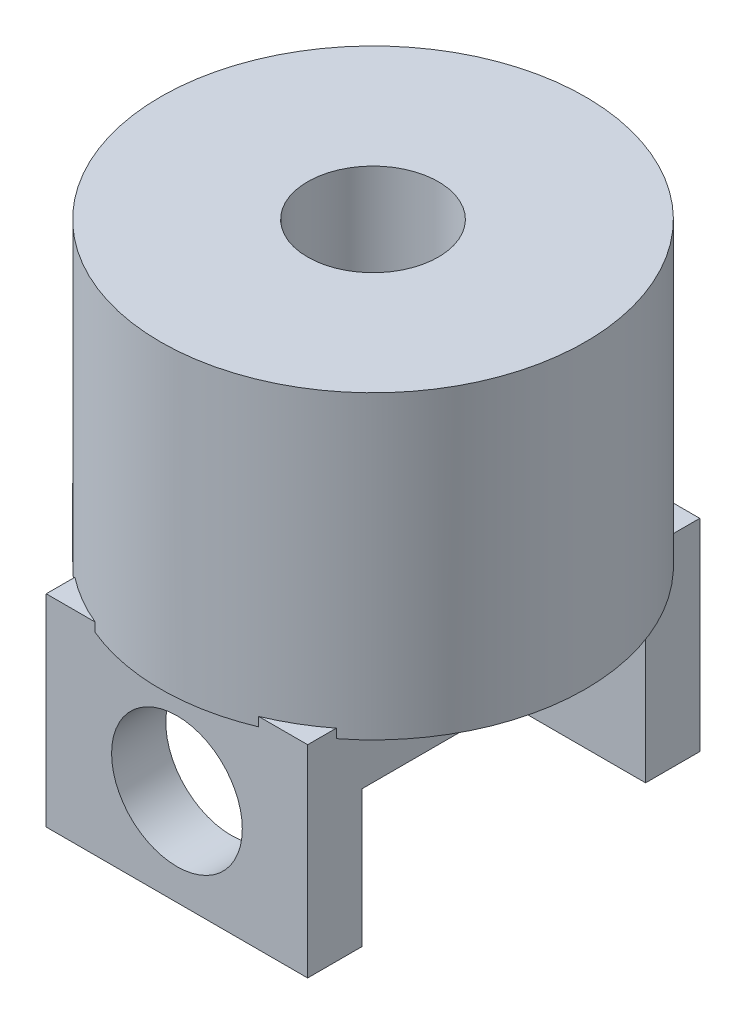
from build123d import *

# Parameters (mm, degrees)
SKETCH1_R           = 32.5
BOSS_EXTRUDE1_DEPTH = 46
SKETCH2_R           = 10
CUT_EXTRUDE1_DEPTH  = 40
BOSS_EXTRUDE2_DEPTH = 20
SKETCH4_R           = 10
CUT_EXTRUDE2_DEPTH  = 42


with BuildPart() as part:
    # Sketch1 → Boss-Extrude1 (new body)
    with BuildSketch(Plane(origin=(0, 0, 0), x_dir=(1, 0, 0), z_dir=(0, 1, 0))):
        Circle(SKETCH1_R)
    extrude(amount=BOSS_EXTRUDE1_DEPTH)

    # Sketch2 → Cut-Extrude1 (cut)
    with BuildSketch(Plane(origin=(0, 46, 0), x_dir=(1, 0, 0), z_dir=(0, 1, 0))):
        Circle(SKETCH2_R)
    extrude(amount=-CUT_EXTRUDE1_DEPTH, mode=Mode.SUBTRACT)

    # Sketch3 → Boss-Extrude2 (add, symmetric)
    with BuildSketch(Plane(origin=(0, 0, 0), x_dir=(0, 0, -1), z_dir=(1, 0, 0))):
        Polygon((30, 1.387692851), (-30, 1.387692851), (-30, -29.525977517), (-21.708955771, -29.525977517), (-21.708955771, -8.612307149), (21.708955771, -8.612307149), (21.708955771, -29.525977517), (30, -29.525977517), align=None)
    extrude(amount=BOSS_EXTRUDE2_DEPTH, both=True)

    # Sketch4 → Cut-Extrude2 (cut, symmetric)
    with BuildSketch(Plane.XY):
        with Locations((0, -14.762988758)):
            Circle(SKETCH4_R)
    extrude(amount=CUT_EXTRUDE2_DEPTH, both=True, mode=Mode.SUBTRACT)


solid = part.part
